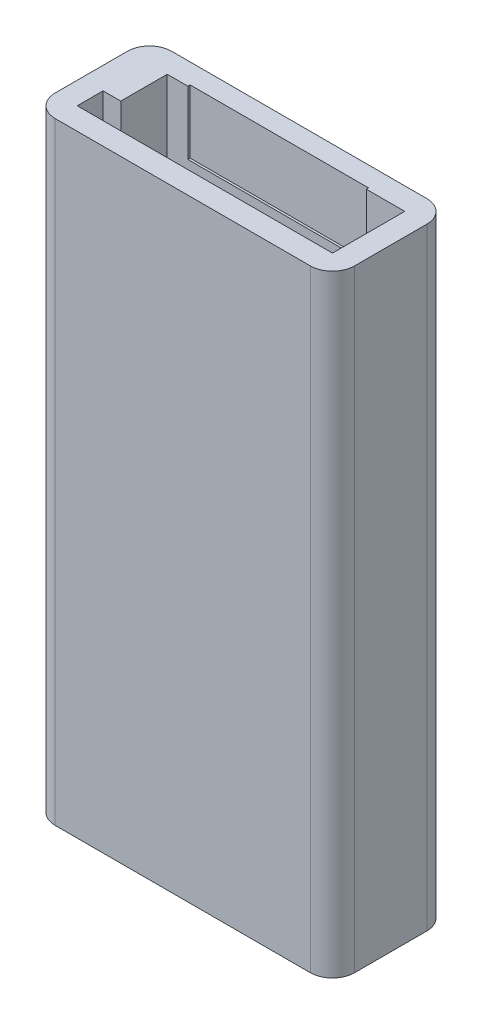
from build123d import *

# Parameters (mm, degrees)
SKETCH1_W           = 20.3
SKETCH1_H           = 7.9
SKETCH1_W_2         = 17.3
SKETCH1_H_2         = 4.9
BOSS_EXTRUDE1_DEPTH = 41.5
SKETCH2_W           = 20.3
SKETCH2_H           = 7.9
BOSS_EXTRUDE2_DEPTH = 1.5
SKETCH3_W           = 1.2
SKETCH3_H           = 3.15
BOSS_EXTRUDE3_DEPTH = 40
SKETCH4_W           = 1.2
SKETCH4_H           = 3.15
BOSS_EXTRUDE4_DEPTH = 17
SKETCH5_W           = 12.1
SKETCH5_H           = 0.3
CUT_EXTRUDE1_DEPTH  = 4.3
FILLET1_R           = 1.5


with BuildPart() as part:
    # Sketch1 → Boss-Extrude1 (new body)
    with BuildSketch(Plane(origin=(0, 0, 0), x_dir=(1, 0, 0), z_dir=(0, 1, 0))):
        Rectangle(SKETCH1_W, SKETCH1_H)
        Rectangle(SKETCH1_W_2, SKETCH1_H_2, mode=Mode.SUBTRACT)
    extrude(amount=BOSS_EXTRUDE1_DEPTH)

    # Sketch2 → Boss-Extrude2 (add)
    with BuildSketch(Plane.XZ):
        Rectangle(SKETCH2_W, SKETCH2_H)
    extrude(amount=-BOSS_EXTRUDE2_DEPTH)

    # Sketch3 → Boss-Extrude3 (add)
    with BuildSketch(Plane(origin=(0, 1.5, 0), x_dir=(1, 0, 0), z_dir=(0, 1, 0))):
        with Locations((-8.05, 0.875)):
            Rectangle(SKETCH3_W, SKETCH3_H)
    extrude(amount=BOSS_EXTRUDE3_DEPTH)

    # Sketch4 → Boss-Extrude4 (add)
    with BuildSketch(Plane(origin=(0, 1.5, 0), x_dir=(1, 0, 0), z_dir=(0, 1, 0))):
        with Locations((8.05, 0.875)):
            Rectangle(SKETCH4_W, SKETCH4_H)
    extrude(amount=BOSS_EXTRUDE4_DEPTH)

    # Sketch5 → Cut-Extrude1 (cut)
    with BuildSketch(Plane(origin=(0, 41.5, 0), x_dir=(1, 0, 0), z_dir=(0, 1, 0))):
        with Locations((0, 2.45)):
            Rectangle(SKETCH5_W, SKETCH5_H)
    extrude(amount=-CUT_EXTRUDE1_DEPTH, mode=Mode.SUBTRACT)

    # Fillet1
    fillet1_edges = [part.edges().sort_by_distance(p)[0] for p in [
        (-10.15, 20.75, 3.95),
        (-10.15, 20.75, -3.95),
        (10.15, 20.75, -3.95),
        (10.15, 20.75, 3.95),
    ]]
    fillet(fillet1_edges, radius=FILLET1_R)


solid = part.part
